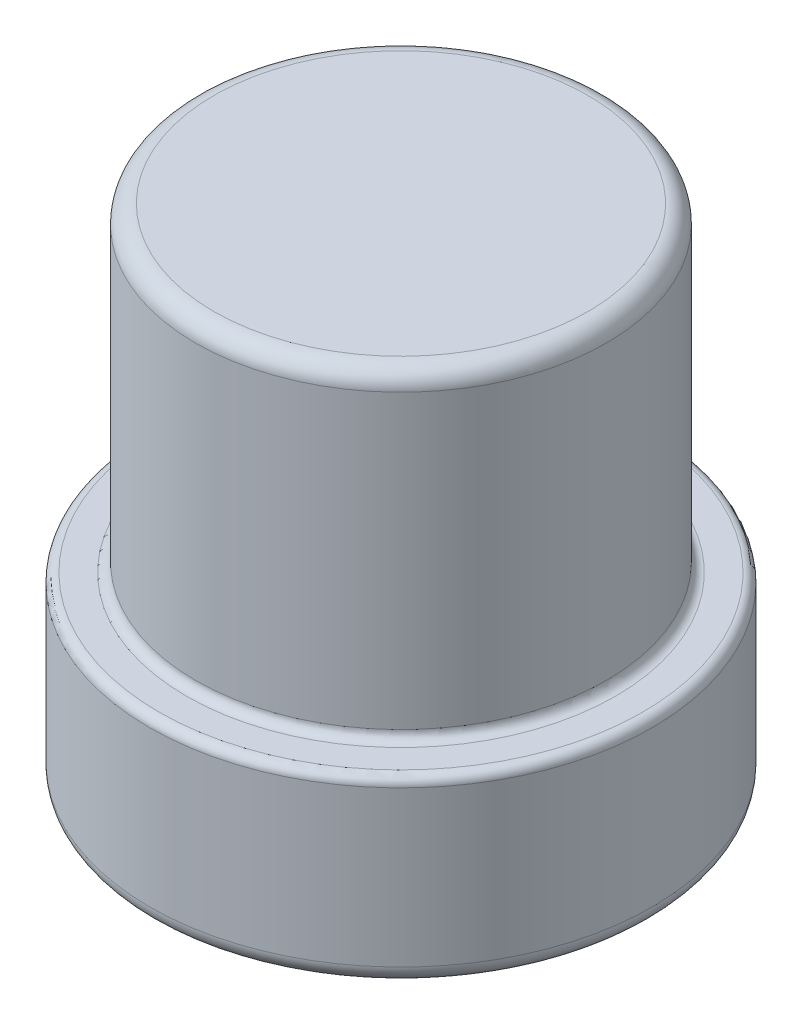
from build123d import *

# Parameters (mm, degrees)
SKETCH_2_R          = 5.5
EXTRUDE_1_DEPTH     = 4
SKETCH_3_R          = 4.5
EXTRUDE_2_DEPTH     = 7
SKETCH_4_R          = 3.5
CUT_EXTRUDE_1_DEPTH = 4.5
FILLET_1_R          = 0.4
FILLET_2_R          = 0.2


with BuildPart() as part:
    # 草图2 → 凸台-拉伸1 (new body)
    with BuildSketch(Plane(origin=(0, 0, 0), x_dir=(1, 0, 0), z_dir=(0, 1, 0))):
        Circle(SKETCH_2_R)
    extrude(amount=EXTRUDE_1_DEPTH)

    # 草图3 → 凸台-拉伸2 (add)
    with BuildSketch(Plane(origin=(0, 4, 0), x_dir=(1, 0, 0), z_dir=(0, 1, 0))):
        Circle(SKETCH_3_R)
    extrude(amount=EXTRUDE_2_DEPTH)

    # 草图4 → 切除-拉伸1 (cut)
    with BuildSketch(Plane.XZ):
        Circle(SKETCH_4_R)
    extrude(amount=-CUT_EXTRUDE_1_DEPTH, mode=Mode.SUBTRACT)

    # 圆角1
    fillet_1_edges = [part.edges().sort_by_distance(p)[0] for p in [
        (-5.5, 0, 0),
        (-3.5, 0, 0),
        (-4.5, 11, 0),
    ]]
    fillet(fillet_1_edges, radius=FILLET_1_R)

    # 圆角2
    fillet_2_edges = [part.edges().sort_by_distance(p)[0] for p in [
        (-5.5, 4, 0),
        (-4.5, 4, 0),
    ]]
    fillet(fillet_2_edges, radius=FILLET_2_R)


solid = part.part
